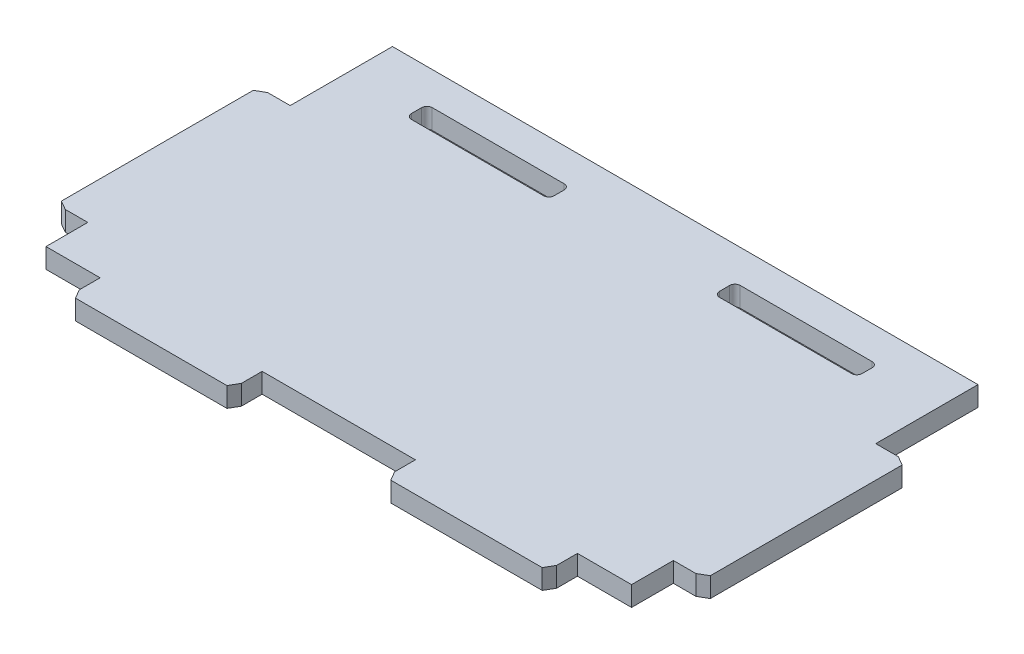
from build123d import *

# Parameters (mm, degrees)
SKETCH1_W             = 93.653112922
SKETCH1_H             = 50
BOSS_EXTRUDE1_DEPTH   = 2.8575
SKETCH3_W             = 23.386037641
SKETCH3_H             = 4.318
BOSS_EXTRUDE2_DEPTH   = 2.8575
CUT_EXTRUDE1_REACH    = 4.857
SKETCH4_W             = 4.572
SKETCH4_H             = 14.7575
SKETCH4_H_2           = 6.0325
CUT_EXTRUDE2_REACH    = 4.857
SKETCH5_W             = 20.574
SKETCH5_H             = 2.9845
SKETCH6_R             = 0.635
CUT_EXTRUDE3_DEPTH    = 0.127
CHAMFER1_SIZE         = 0.762
CHAMFER1_SIZE2        = 1.319822715
CHAMFER1_PART_2_SIZE  = 0.762
CHAMFER1_PART_2_SIZE2 = 1.319822715
CHAMFER1_PART_3_SIZE  = 0.762
CHAMFER1_PART_3_SIZE2 = 1.319822715
CHAMFER1_PART_4_SIZE  = 0.762
CHAMFER1_PART_4_SIZE2 = 1.319822715
CHAMFER2_SIZE         = 0.762
CHAMFER2_SIZE2        = 1.319822715
CHAMFER2_PART_2_SIZE  = 0.762
CHAMFER2_PART_2_SIZE2 = 1.319822715
CHAMFER2_PART_3_SIZE  = 0.762
CHAMFER2_PART_3_SIZE2 = 1.319822715
CHAMFER2_PART_4_SIZE  = 0.762
CHAMFER2_PART_4_SIZE2 = 1.319822715
FILLET1_R             = 0.762


with BuildPart() as part:
    # Sketch1 → Boss-Extrude1 (new body)
    with BuildSketch(Plane(origin=(0, 0, 0), x_dir=(1, 0, 0), z_dir=(0, 1, 0))):
        Rectangle(SKETCH1_W, SKETCH1_H)
    extrude(amount=BOSS_EXTRUDE1_DEPTH)

    # Sketch3 → Boss-Extrude2 (add)
    with BuildSketch(Plane.XZ):
        with Locations((-22.751037641, 27.159)):
            Rectangle(SKETCH3_W, SKETCH3_H)
        with Locations((22.751037641, 27.159)):
            Rectangle(SKETCH3_W, SKETCH3_H)
    extrude(amount=-BOSS_EXTRUDE2_DEPTH)

    # Sketch4 → Cut-Extrude1 (cut, up to next)
    with BuildSketch(Plane(origin=(0, 2.8575, 0), x_dir=(1, 0, 0), z_dir=(0, 1, 0)), mode=Mode.PRIVATE) as cut_extrude1_sk1:
        with Locations((44.540556461, 17.62125)):
            Rectangle(SKETCH4_W, SKETCH4_H)
    cut_extrude1_tool1 = extrude(cut_extrude1_sk1.sketch, amount=-CUT_EXTRUDE1_REACH, mode=Mode.PRIVATE) & part.part
    add(cut_extrude1_tool1.solids().sort_by_distance((44.540556, 2.8575, -17.62125))[0], mode=Mode.SUBTRACT)
    # Sketch4 → Cut-Extrude1 (cut, up to next)
    with BuildSketch(Plane(origin=(0, 2.8575, 0), x_dir=(1, 0, 0), z_dir=(0, 1, 0)), mode=Mode.PRIVATE) as cut_extrude1_sk2:
        with Locations((44.540556461, -21.98375)):
            Rectangle(SKETCH4_W, SKETCH4_H_2)
    cut_extrude1_tool2 = extrude(cut_extrude1_sk2.sketch, amount=-CUT_EXTRUDE1_REACH, mode=Mode.PRIVATE) & part.part
    add(cut_extrude1_tool2.solids().sort_by_distance((44.540556, 2.8575, 21.98375))[0], mode=Mode.SUBTRACT)
    # Sketch4 → Cut-Extrude1 (cut, up to next)
    with BuildSketch(Plane(origin=(0, 2.8575, 0), x_dir=(1, 0, 0), z_dir=(0, 1, 0)), mode=Mode.PRIVATE) as cut_extrude1_sk3:
        with Locations((-44.540556461, 17.62125)):
            Rectangle(SKETCH4_W, SKETCH4_H)
    cut_extrude1_tool3 = extrude(cut_extrude1_sk3.sketch, amount=-CUT_EXTRUDE1_REACH, mode=Mode.PRIVATE) & part.part
    add(cut_extrude1_tool3.solids().sort_by_distance((-44.540556, 2.8575, -17.62125))[0], mode=Mode.SUBTRACT)
    # Sketch4 → Cut-Extrude1 (cut, up to next)
    with BuildSketch(Plane(origin=(0, 2.8575, 0), x_dir=(1, 0, 0), z_dir=(0, 1, 0)), mode=Mode.PRIVATE) as cut_extrude1_sk4:
        with Locations((-44.540556461, -21.98375)):
            Rectangle(SKETCH4_W, SKETCH4_H_2)
    cut_extrude1_tool4 = extrude(cut_extrude1_sk4.sketch, amount=-CUT_EXTRUDE1_REACH, mode=Mode.PRIVATE) & part.part
    add(cut_extrude1_tool4.solids().sort_by_distance((-44.540556, 2.8575, 21.98375))[0], mode=Mode.SUBTRACT)

    # Sketch5 → Cut-Extrude2 (cut, up to next)
    with BuildSketch(Plane.XZ, mode=Mode.PRIVATE) as cut_extrude2_sk1:
        with Locations((22.225, -18.74525)):
            Rectangle(SKETCH5_W, SKETCH5_H)
    cut_extrude2_tool1 = extrude(cut_extrude2_sk1.sketch, amount=-CUT_EXTRUDE2_REACH, mode=Mode.PRIVATE) & part.part
    add(cut_extrude2_tool1.solids().sort_by_distance((22.225, 0, -18.74525))[0], mode=Mode.SUBTRACT)
    # Sketch5 → Cut-Extrude2 (cut, up to next)
    with BuildSketch(Plane.XZ, mode=Mode.PRIVATE) as cut_extrude2_sk2:
        with Locations((-22.225, -18.74525)):
            Rectangle(SKETCH5_W, SKETCH5_H)
    cut_extrude2_tool2 = extrude(cut_extrude2_sk2.sketch, amount=-CUT_EXTRUDE2_REACH, mode=Mode.PRIVATE) & part.part
    add(cut_extrude2_tool2.solids().sort_by_distance((-22.225, 0, -18.74525))[0], mode=Mode.SUBTRACT)

    # Sketch6 → Cut-Extrude3 (cut)
    with BuildSketch(Plane.XZ):
        with Locations((-25.799037641, 26.778)):
            Circle(SKETCH6_R)
        with Locations((-23.767037641, 26.778)):
            Circle(SKETCH6_R)
        with Locations((-21.735037641, 26.778)):
            Circle(SKETCH6_R)
        with Locations((-19.703037641, 26.778)):
            Circle(SKETCH6_R)
        with Locations((19.703037641, 26.778)):
            Circle(SKETCH6_R)
        with Locations((21.735037641, 26.778)):
            Circle(SKETCH6_R)
        with Locations((23.767037641, 26.778)):
            Circle(SKETCH6_R)
        with Locations((25.799037641, 26.778)):
            Circle(SKETCH6_R)
        with Locations((44.286556461, 4.3625)):
            Circle(SKETCH6_R)
        with Locations((-44.286556461, 7.4105)):
            Circle(SKETCH6_R)
        with Locations((-44.286556461, 5.3785)):
            Circle(SKETCH6_R)
        with Locations((-44.286556461, 3.3465)):
            Circle(SKETCH6_R)
        with Locations((-44.286556461, 1.3145)):
            Circle(SKETCH6_R)
    extrude(amount=-CUT_EXTRUDE3_DEPTH, mode=Mode.SUBTRACT)

    # Chamfer1
    chamfer1_edges = [part.edges().sort_by_distance(p)[0] for p in [
        (-34.444056461, 1.42875, 29.318),
    ]]
    chamfer1_side = [part.faces().sort_by_distance(p)[0] for p in [
        (-22.751037641, 1.42875, 29.318),
    ]]
    chamfer(chamfer1_edges, length=CHAMFER1_SIZE, length2=CHAMFER1_SIZE2, reference=chamfer1_side[0])

    # Chamfer1 part 2
    chamfer1_part_2_edges = [part.edges().sort_by_distance(p)[0] for p in [
        (11.05801882, 1.42875, 29.318),
    ]]
    chamfer1_part_2_side = [part.faces().sort_by_distance(p)[0] for p in [
        (22.751037641, 1.42875, 29.318),
    ]]
    chamfer(chamfer1_part_2_edges, length=CHAMFER1_PART_2_SIZE, length2=CHAMFER1_PART_2_SIZE2, reference=chamfer1_part_2_side[0])

    # Chamfer1 part 3
    chamfer1_part_3_edges = [part.edges().sort_by_distance(p)[0] for p in [
        (-46.826556461, 1.42875, 18.9675),
    ]]
    chamfer1_part_3_side = [part.faces().sort_by_distance(p)[0] for p in [
        (-46.826556461, 1.42875, 4.3625),
    ]]
    chamfer(chamfer1_part_3_edges, length=CHAMFER1_PART_3_SIZE, length2=CHAMFER1_PART_3_SIZE2, reference=chamfer1_part_3_side[0])

    # Chamfer1 part 4
    chamfer1_part_4_edges = [part.edges().sort_by_distance(p)[0] for p in [
        (46.826556461, 1.42875, -10.2425),
    ]]
    chamfer1_part_4_side = [part.faces().sort_by_distance(p)[0] for p in [
        (46.826556461, 1.42875, 4.3625),
    ]]
    chamfer(chamfer1_part_4_edges, length=CHAMFER1_PART_4_SIZE, length2=CHAMFER1_PART_4_SIZE2, reference=chamfer1_part_4_side[0])

    # Chamfer2
    chamfer2_edges = [part.edges().sort_by_distance(p)[0] for p in [
        (-11.05801882, 1.42875, 29.318),
    ]]
    chamfer2_side = [part.faces().sort_by_distance(p)[0] for p in [
        (-22.370037641, 1.42875, 29.318),
    ]]
    chamfer(chamfer2_edges, length=CHAMFER2_SIZE, length2=CHAMFER2_SIZE2, reference=chamfer2_side[0])

    # Chamfer2 part 2
    chamfer2_part_2_edges = [part.edges().sort_by_distance(p)[0] for p in [
        (34.444056461, 1.42875, 29.318),
    ]]
    chamfer2_part_2_side = [part.faces().sort_by_distance(p)[0] for p in [
        (23.132037641, 1.42875, 29.318),
    ]]
    chamfer(chamfer2_part_2_edges, length=CHAMFER2_PART_2_SIZE, length2=CHAMFER2_PART_2_SIZE2, reference=chamfer2_part_2_side[0])

    # Chamfer2 part 3
    chamfer2_part_3_edges = [part.edges().sort_by_distance(p)[0] for p in [
        (46.826556461, 1.42875, 18.9675),
    ]]
    chamfer2_part_3_side = [part.faces().sort_by_distance(p)[0] for p in [
        (46.826556461, 1.42875, 4.7435),
    ]]
    chamfer(chamfer2_part_3_edges, length=CHAMFER2_PART_3_SIZE, length2=CHAMFER2_PART_3_SIZE2, reference=chamfer2_part_3_side[0])

    # Chamfer2 part 4
    chamfer2_part_4_edges = [part.edges().sort_by_distance(p)[0] for p in [
        (-46.826556461, 1.42875, -10.2425),
    ]]
    chamfer2_part_4_side = [part.faces().sort_by_distance(p)[0] for p in [
        (-46.826556461, 1.42875, 3.9815),
    ]]
    chamfer(chamfer2_part_4_edges, length=CHAMFER2_PART_4_SIZE, length2=CHAMFER2_PART_4_SIZE2, reference=chamfer2_part_4_side[0])

    # Fillet1
    fillet1_edges = [part.edges().sort_by_distance(p)[0] for p in [
        (11.938, 1.42875, -20.2375),
        (11.938, 1.42875, -17.253),
        (32.512, 1.42875, -17.253),
        (32.512, 1.42875, -20.2375),
        (-32.512, 1.42875, -20.2375),
        (-32.512, 1.42875, -17.253),
        (-11.938, 1.42875, -17.253),
        (-11.938, 1.42875, -20.2375),
    ]]
    fillet(fillet1_edges, radius=FILLET1_R)


solid = part.part
